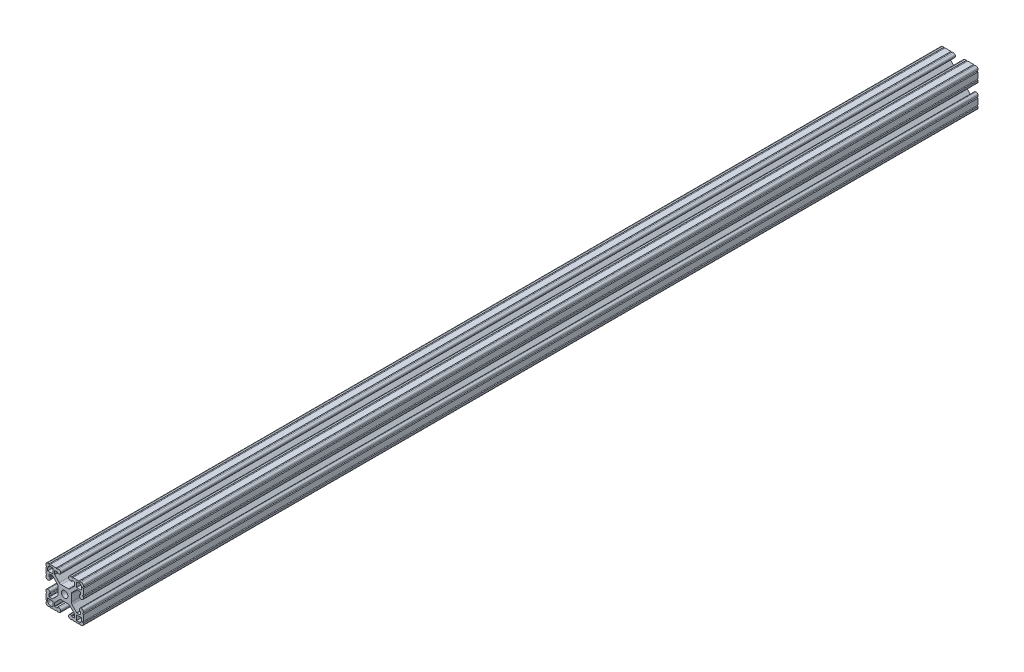
from build123d import *

# Parameters (mm, degrees)
SKETCH3_W                = 38.1
SKETCH3_H                = 38.1
BOSS_EXTRUDE1_DEPTH      = 457.2
BOSS_EXTRUDE1_DEPTH_BACK = 457.2
SKETCH4_W                = 5.207
SKETCH4_H                = 5.207
SKETCH4_R                = 3.3274
CUT_EXTRUDE1_DEPTH       = 915.4
CUT_EXTRUDE2_DEPTH       = 915.4
FILLET1_R                = 2.54
FILLET2_R                = 1.778
FILLET3_R                = 0.396875


with BuildPart() as part:
    # Sketch3 → Boss-Extrude1 (new body, two sides)
    with BuildSketch(Plane.XY) as boss_extrude1_sk:
        Rectangle(SKETCH3_W, SKETCH3_H)
    extrude(amount=BOSS_EXTRUDE1_DEPTH)
    extrude(boss_extrude1_sk.sketch, amount=-BOSS_EXTRUDE1_DEPTH_BACK)

    # Sketch4 → Cut-Extrude1 (cut, through all)
    with BuildSketch(Plane.XY.offset(457.2)):
        Polygon((7.239, 14.986), (4.064, 14.986), (4.064, 19.05), (-4.064, 19.05), (-4.064, 14.986), (-7.239, 14.986), (-7.239, 16.002), (-10.287, 16.002), (-10.287, 12.442261469), (-4.601138531, 6.7564), (4.601138531, 6.7564), (10.287, 12.442261469), (10.287, 16.002), (7.239, 16.002), align=None)
        Polygon((10.287, -12.442261469), (4.601138531, -6.7564), (-4.601138531, -6.7564), (-10.287, -12.442261469), (-10.287, -16.002), (-7.239, -16.002), (-7.239, -14.986), (-4.064, -14.986), (-4.064, -19.05), (4.064, -19.05), (4.064, -14.986), (7.239, -14.986), (7.239, -16.002), (10.287, -16.002), align=None)
        Polygon((-12.442261469, -10.287), (-6.7564, -4.601138531), (-6.7564, 4.601138531), (-12.442261469, 10.287), (-16.002, 10.287), (-16.002, 7.239), (-14.986, 7.239), (-14.986, 4.064), (-19.05, 4.064), (-19.05, -4.064), (-14.986, -4.064), (-14.986, -7.239), (-16.002, -7.239), (-16.002, -10.287), align=None)
        Polygon((14.986, -7.239), (14.986, -4.064), (19.05, -4.064), (19.05, 4.064), (14.986, 4.064), (14.986, 7.239), (16.002, 7.239), (16.002, 10.287), (12.442261469, 10.287), (6.7564, 4.601138531), (6.7564, -4.601138531), (12.442261469, -10.287), (16.002, -10.287), (16.002, -7.239), align=None)
        with Locations((14.6685, 14.6685)):
            Rectangle(SKETCH4_W, SKETCH4_H)
        with Locations((14.6685, -14.6685)):
            Rectangle(SKETCH4_W, SKETCH4_H)
        with Locations((-14.6685, 14.6685)):
            Rectangle(SKETCH4_W, SKETCH4_H)
        with Locations((-14.6685, -14.6685)):
            Rectangle(SKETCH4_W, SKETCH4_H)
        Circle(SKETCH4_R)
    extrude(amount=-CUT_EXTRUDE1_DEPTH, mode=Mode.SUBTRACT)

    # Sketch5 → Cut-Extrude2 (cut, through all)
    with BuildSketch(Plane.XY.offset(457.2)):
        with BuildLine():
            Line((-14.605, 19.05), (-15.875, 19.05))
            ThreePointArc((-15.875, 19.05), (-15.24, 18.415), (-14.605, 19.05))
        make_face()
        with BuildLine():
            Line((-7.239, 19.05), (-8.509, 19.05))
            ThreePointArc((-8.509, 19.05), (-7.874, 18.415), (-7.239, 19.05))
        make_face()
        with BuildLine():
            ThreePointArc((-19.05, 14.605), (-18.415, 15.24), (-19.05, 15.875))
            Line((-19.05, 15.875), (-19.05, 14.605))
        make_face()
        with BuildLine():
            ThreePointArc((-19.05, 7.239), (-18.415, 7.874), (-19.05, 8.509))
            Line((-19.05, 8.509), (-19.05, 7.239))
        make_face()
        with BuildLine():
            ThreePointArc((7.239, 19.05), (7.874, 18.415), (8.509, 19.05))
            Line((8.509, 19.05), (7.239, 19.05))
        make_face()
        with BuildLine():
            ThreePointArc((14.605, 19.05), (15.24, 18.415), (15.875, 19.05))
            Line((15.875, 19.05), (14.605, 19.05))
        make_face()
        with BuildLine():
            Line((19.05, 14.605), (19.05, 15.875))
            ThreePointArc((19.05, 15.875), (18.415, 15.24), (19.05, 14.605))
        make_face()
        with BuildLine():
            Line((19.05, 7.239), (19.05, 8.509))
            ThreePointArc((19.05, 8.509), (18.415, 7.874), (19.05, 7.239))
        make_face()
        with BuildLine():
            ThreePointArc((19.05, -7.239), (18.415, -7.874), (19.05, -8.509))
            Line((19.05, -8.509), (19.05, -7.239))
        make_face()
        with BuildLine():
            ThreePointArc((19.05, -14.605), (18.415, -15.24), (19.05, -15.875))
            Line((19.05, -15.875), (19.05, -14.605))
        make_face()
        with BuildLine():
            Line((14.605, -19.05), (15.875, -19.05))
            ThreePointArc((15.875, -19.05), (15.24, -18.415), (14.605, -19.05))
        make_face()
        with BuildLine():
            Line((7.239, -19.05), (8.509, -19.05))
            ThreePointArc((8.509, -19.05), (7.874, -18.415), (7.239, -19.05))
        make_face()
        with BuildLine():
            ThreePointArc((-7.239, -19.05), (-7.874, -18.415), (-8.509, -19.05))
            Line((-8.509, -19.05), (-7.239, -19.05))
        make_face()
        with BuildLine():
            ThreePointArc((-14.605, -19.05), (-15.24, -18.415), (-15.875, -19.05))
            Line((-15.875, -19.05), (-14.605, -19.05))
        make_face()
        with BuildLine():
            Line((-19.05, -14.605), (-19.05, -15.875))
            ThreePointArc((-19.05, -15.875), (-18.415, -15.24), (-19.05, -14.605))
        make_face()
        with BuildLine():
            Line((-19.05, -7.239), (-19.05, -8.509))
            ThreePointArc((-19.05, -8.509), (-18.415, -7.874), (-19.05, -7.239))
        make_face()
    extrude(amount=-CUT_EXTRUDE2_DEPTH, mode=Mode.SUBTRACT)

    # Fillet1
    fillet1_edges = [part.edges().sort_by_distance(p)[0] for p in [
        (6.7564, -4.601138531, 0),
        (6.7564, 4.601138531, 0),
        (-17.272, 17.272, 0),
        (-17.272, -17.272, 0),
        (17.272, -17.272, 0),
        (17.272, 17.272, 0),
        (-4.601138531, -6.7564, 0),
        (4.601138531, -6.7564, 0),
        (-6.7564, 4.601138531, 0),
        (-6.7564, -4.601138531, 0),
        (4.601138531, 6.7564, 0),
        (-4.601138531, 6.7564, 0),
    ]]
    fillet(fillet1_edges, radius=FILLET1_R)

    # Fillet2
    fillet2_edges = [part.edges().sort_by_distance(p)[0] for p in [
        (14.986, 4.064, 0),
        (19.05, 4.064, 0),
        (19.05, -4.064, 0),
        (14.986, -4.064, 0),
        (4.064, -14.986, 0),
        (4.064, -19.05, 0),
        (-4.064, -19.05, 0),
        (-4.064, -14.986, 0),
        (-14.986, -4.064, 0),
        (-19.05, -4.064, 0),
        (-19.05, 4.064, 0),
        (-14.986, 4.064, 0),
        (-19.05, 19.05, 0),
        (19.05, 19.05, 0),
        (19.05, -19.05, 0),
        (-19.05, -19.05, 0),
        (-4.064, 14.986, 0),
        (-4.064, 19.05, 0),
        (4.064, 19.05, 0),
        (4.064, 14.986, 0),
    ]]
    fillet(fillet2_edges, radius=FILLET2_R)

    # Fillet3
    fillet3_edges = [part.edges().sort_by_distance(p)[0] for p in [
        (12.442261469, 10.287, 0),
        (16.002, 10.287, 0),
        (16.002, 7.239, 0),
        (16.002, -7.239, 0),
        (16.002, -10.287, 0),
        (12.442261469, -10.287, 0),
        (-7.239, -16.002, 0),
        (-10.287, -16.002, 0),
        (-10.287, -12.442261469, 0),
        (10.287, -12.442261469, 0),
        (10.287, -16.002, 0),
        (7.239, -16.002, 0),
        (-16.002, 7.239, 0),
        (-16.002, 10.287, 0),
        (-12.442261469, 10.287, 0),
        (-12.442261469, -10.287, 0),
        (-16.002, -10.287, 0),
        (-14.986, -7.239, 0),
        (-10.287, 12.442261469, 0),
        (-10.287, 16.002, 0),
        (-7.239, 16.002, 0),
        (7.239, 16.002, 0),
        (10.287, 16.002, 0),
        (10.287, 12.442261469, 0),
    ]]
    fillet(fillet3_edges, radius=FILLET3_R)


solid = part.part
